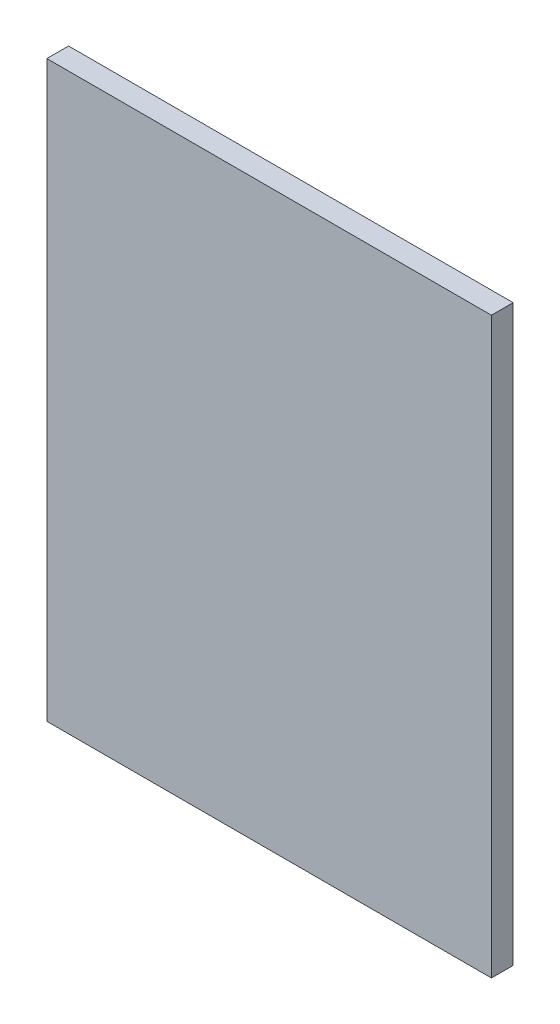
from build123d import *

# Parameters (mm, degrees)
SKETCH1_W           = 57.15
SKETCH1_H           = 73.787
BOSS_EXTRUDE1_DEPTH = 2.794


with BuildPart() as part:
    # Sketch1 → Boss-Extrude1 (new body)
    with BuildSketch(Plane.XY):
        with Locations((28.575, -36.8935)):
            Rectangle(SKETCH1_W, SKETCH1_H)
    extrude(amount=BOSS_EXTRUDE1_DEPTH)


solid = part.part
